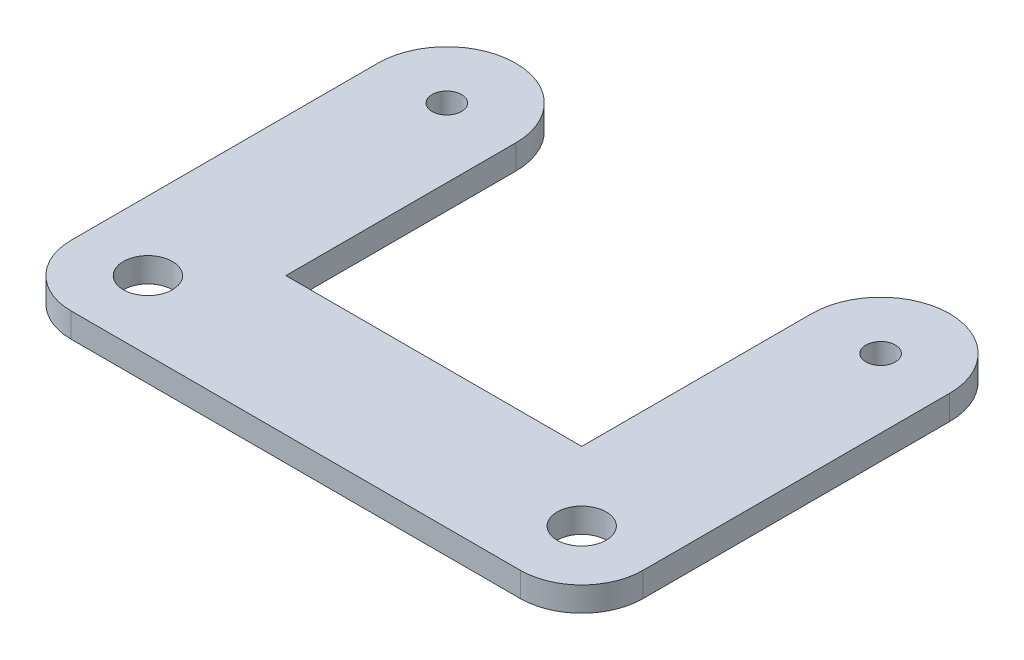
from build123d import *

# Parameters (mm, degrees)
SKETCH1_R           = 4
SKETCH1_R_2         = 11.25
SKETCH1_R_3         = 2.4
BOSS_EXTRUDE1_DEPTH = 4
FILLET1_R           = 10


with BuildPart() as part:
    # Sketch1 → Boss-Extrude1 (new body)
    with BuildSketch(Plane(origin=(0, 0, 0), x_dir=(1, 0, 0), z_dir=(0, 1, 0))):
        with BuildLine():
            Line((-24.125, -37.5), (-24.125, 0))
            ThreePointArc((-24.125, 0), (-35.375, -11.25), (-46.625, 0))
            Line((-46.625, 0), (-46.625, -60))
            Line((-46.625, -60), (46.625, -60))
            Line((46.625, -60), (46.625, 0))
            ThreePointArc((46.625, 0), (35.375, -11.25), (24.125, 0))
            Line((24.125, 0), (24.125, -37.5))
            Line((24.125, -37.5), (-24.125, -37.5))
        make_face()
        with Locations((-35.375, -48.75)):
            Circle(SKETCH1_R, mode=Mode.SUBTRACT)
        with Locations((35.375, -48.75)):
            Circle(SKETCH1_R, mode=Mode.SUBTRACT)
        with Locations((-35.375, 0)):
            Circle(SKETCH1_R_2)
        with Locations((-35.375, 0)):
            Circle(SKETCH1_R_3, mode=Mode.SUBTRACT)
        with Locations((35.375, 0)):
            Circle(SKETCH1_R_2)
        with Locations((35.375, 0)):
            Circle(SKETCH1_R_3, mode=Mode.SUBTRACT)
    extrude(amount=BOSS_EXTRUDE1_DEPTH)

    # Fillet1
    fillet1_edges = [part.edges().sort_by_distance(p)[0] for p in [
        (46.625, 2, 60),
        (-46.625, 2, 60),
    ]]
    fillet(fillet1_edges, radius=FILLET1_R)


solid = part.part
